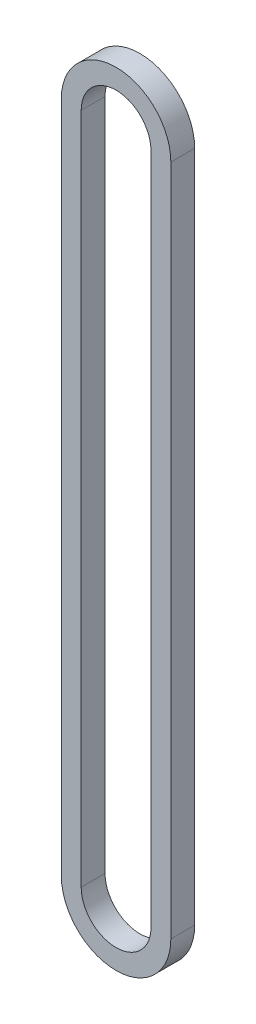
from build123d import *

# Parameters (mm, degrees)
BOSS_EXTRUDE1_DEPTH = 7.62


with BuildPart() as part:
    # Sketch1 → Boss-Extrude1 (new body)
    with BuildSketch(Plane.XY):
        with BuildLine():
            Line((-17.5006, 0), (-17.5006, 215))
            ThreePointArc((-17.5006, 215), (0, 232.5006), (17.5006, 215))
            Line((17.5006, 215), (17.5006, 0))
            ThreePointArc((17.5006, 0), (0, -17.5006), (-17.5006, 0))
        make_face()
        with BuildLine():
            Line((-11.1506, 0), (-11.1506, 215))
            ThreePointArc((-11.1506, 215), (0, 226.1506), (11.1506, 215))
            Line((11.1506, 215), (11.1506, 0))
            ThreePointArc((11.1506, 0), (0, -11.1506), (-11.1506, 0))
        make_face(mode=Mode.SUBTRACT)
    extrude(amount=BOSS_EXTRUDE1_DEPTH)


solid = part.part
